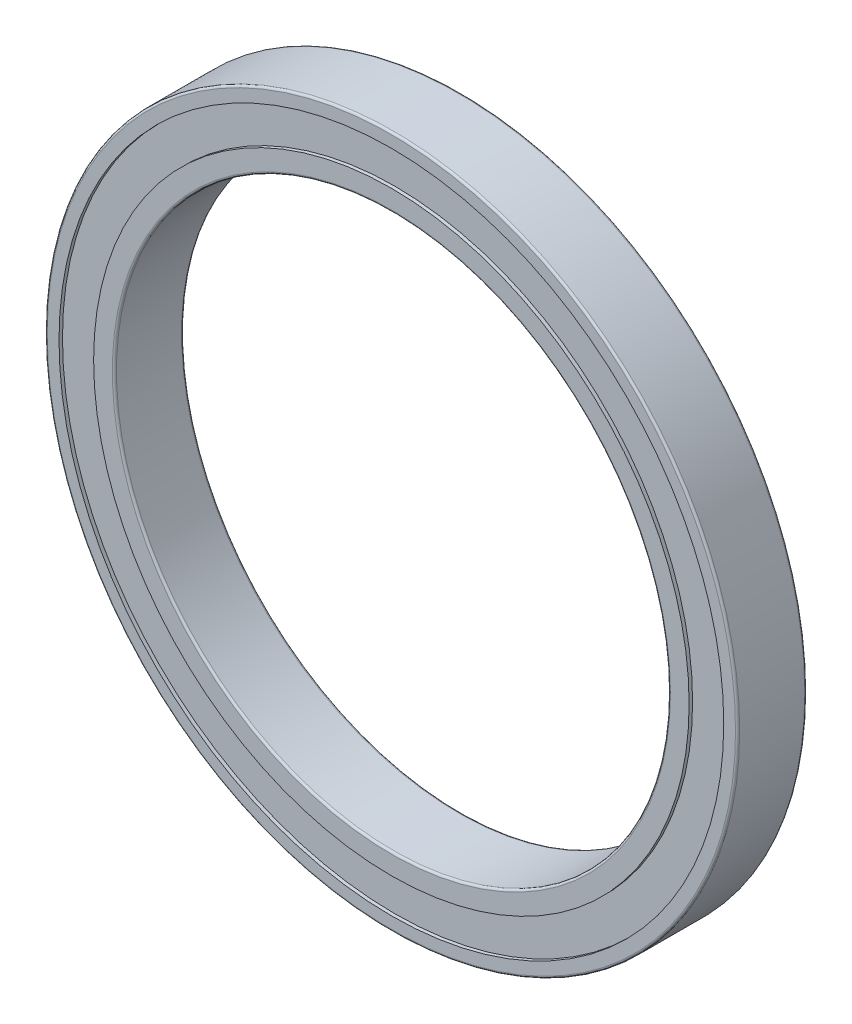
from build123d import *

# Parameters (mm, degrees)
ESQUISSE1_R             = 50
ESQUISSE1_R_2           = 40
BOSS_EXTRU_1_DEPTH      = 10
ESQUISSE2_R             = 48
ESQUISSE2_R_2           = 43
ENL_V_MAT_EXTRU_1_DEPTH = 0.5
ESQUISSE3_R             = 48
ESQUISSE3_R_2           = 43
ENL_V_MAT_EXTRU_2_DEPTH = 0.5
CONG_1_R                = 0.3


with BuildPart() as part:
    # Esquisse1 → Boss.-Extru.1 (new body)
    with BuildSketch(Plane.XY):
        Circle(ESQUISSE1_R)
        Circle(ESQUISSE1_R_2, mode=Mode.SUBTRACT)
    extrude(amount=BOSS_EXTRU_1_DEPTH)

    # Esquisse2 → Enlèv. mat.-Extru.1 (cut)
    with BuildSketch(Plane.XY.offset(10)):
        Circle(ESQUISSE2_R)
        Circle(ESQUISSE2_R_2, mode=Mode.SUBTRACT)
    extrude(amount=-ENL_V_MAT_EXTRU_1_DEPTH, mode=Mode.SUBTRACT)

    # Esquisse3 → Enlèv. mat.-Extru.2 (cut)
    with BuildSketch(Plane(origin=(0, 0, 0), x_dir=(-1, 0, 0), z_dir=(0, 0, -1))):
        Circle(ESQUISSE3_R)
        Circle(ESQUISSE3_R_2, mode=Mode.SUBTRACT)
    extrude(amount=-ENL_V_MAT_EXTRU_2_DEPTH, mode=Mode.SUBTRACT)

    # Congé1
    cong_1_edges = [part.edges().sort_by_distance(p)[0] for p in [
        (-50, 0, 0),
        (-50, 0, 10),
        (-40, 0, 0),
        (-40, 0, 10),
    ]]
    fillet(cong_1_edges, radius=CONG_1_R)


solid = part.part
